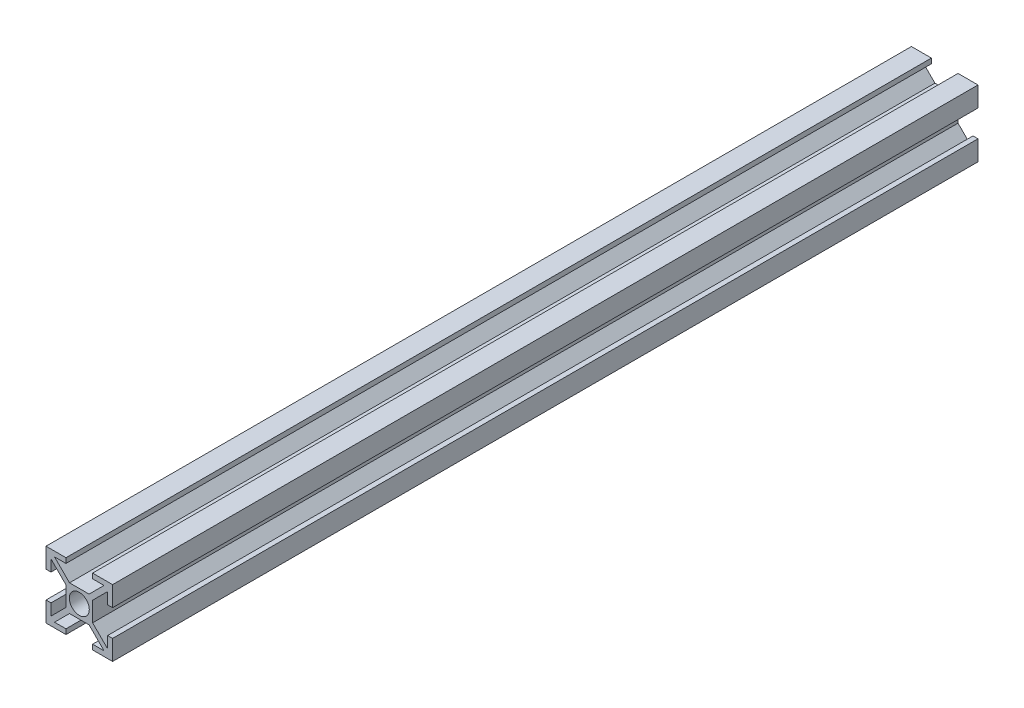
from build123d import *

# Parameters (mm, degrees)
ESBO_O1_R                = 3
RESSALTO_EXTRUS_O1_DEPTH = 260


with BuildPart() as part:
    # Esboço1 → Ressalto-extrusão1 (new body)
    with BuildSketch(Plane.XY):
        Polygon((-2.939339828, 4), (2.939339828, 4), (7.439339828, 8.5), (4, 8.5), (4, 10), (10, 10), (10, 4), (8.5, 4), (8.5, 7.439339828), (4, 2.939339828), (4, -2.939339828), (8.5, -7.439339828), (8.5, -4), (10, -4), (10, -10), (4, -10), (4, -8.5), (7.439339828, -8.5), (2.939339828, -4), (-2.939339828, -4), (-7.439339828, -8.5), (-4, -8.5), (-4, -10), (-10, -10), (-10, -4), (-8.5, -4), (-8.5, -7.439339828), (-4, -2.939339828), (-4, 2.939339828), (-8.5, 7.439339828), (-8.5, 4), (-10, 4), (-10, 10), (-4, 10), (-4, 8.5), (-7.439339828, 8.5), align=None)
        Circle(ESBO_O1_R, mode=Mode.SUBTRACT)
    extrude(amount=RESSALTO_EXTRUS_O1_DEPTH)


solid = part.part
